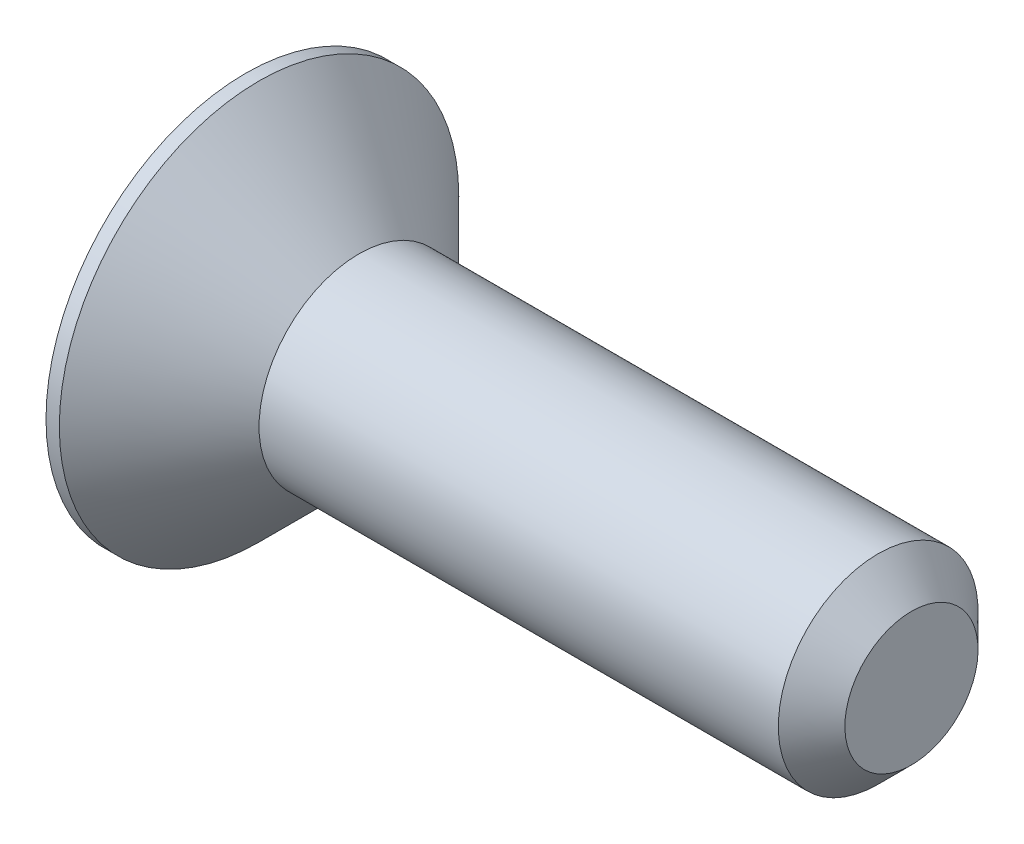
from build123d import *

# Parameters (mm, degrees)
CHANFREIN1_SIZE         = 0.5
ENL_V_MAT_EXTRU_1_DEPTH = 1.2


with BuildPart() as part:
    # Esquisse1 → Révolution1 (revolve)
    with BuildSketch(Plane.XY):
        Polygon((0, 0), (0, 3), (0.2, 3), (1.7, 1.5), (10, 1.5), (10, 0), align=None)
    revolve(axis=Axis((10, 0, 0), (-1, 0, 0)))

    # Chanfrein1
    chanfrein1_edges = [part.edges().sort_by_distance(p)[0] for p in [
        (10, -1.5, 0),
    ]]
    chamfer(chanfrein1_edges, length=CHANFREIN1_SIZE)

    # Esquisse2 → Enlèv. mat.-Extru.1 (cut)
    with BuildSketch(Plane.ZY):
        Polygon((0, 1.154700538), (-1, 0.577350269), (-1, -0.577350269), (0, -1.154700538), (1, -0.577350269), (1, 0.577350269), align=None)
    extrude(amount=-ENL_V_MAT_EXTRU_1_DEPTH, mode=Mode.SUBTRACT)


solid = part.part
